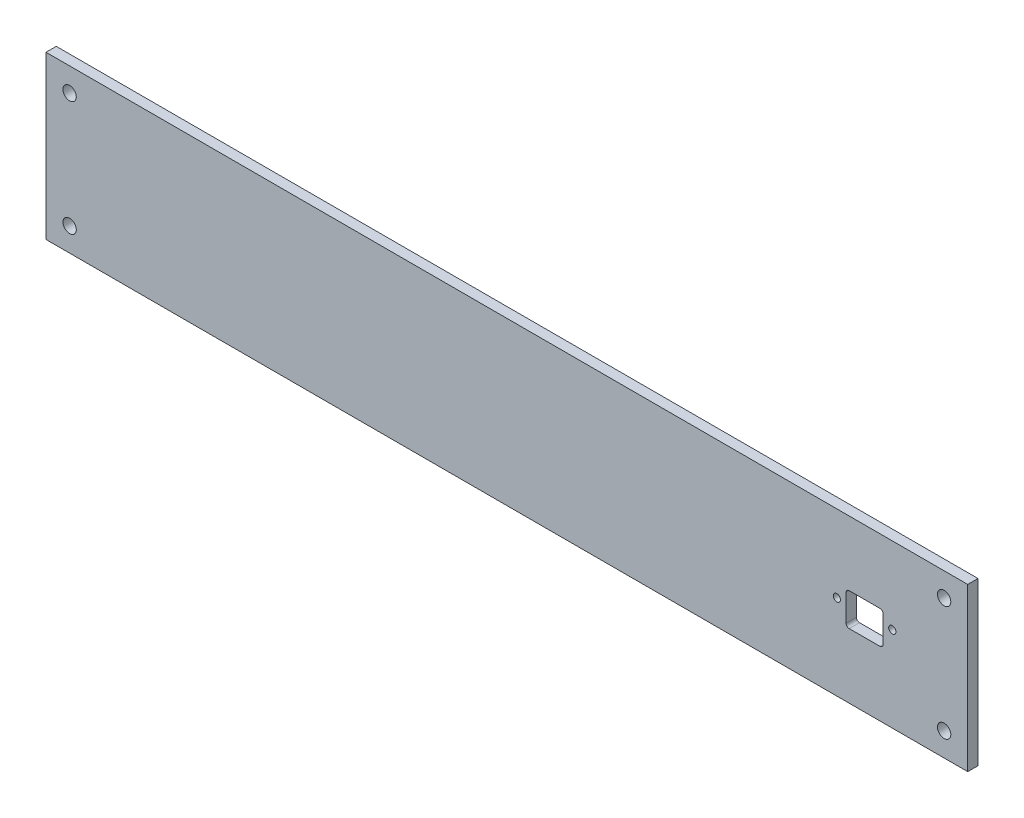
from build123d import *

# Parameters (mm, degrees)
SKETCH_F_W                   = 449
SKETCH_F_H                   = 79
SKETCH_F_R                   = 3.25
SKETCH_F_R_2                 = 1.75
ESTRUSIONE_ESTRUSIONE1_DEPTH = 5


with BuildPart() as part:
    # Sketch f → Estrusione-Estrusione1 (new body)
    with BuildSketch(Plane.XY):
        with Locations((224.5, 39.5)):
            Rectangle(SKETCH_F_W, SKETCH_F_H)
        with Locations((11.5, 67.5)):
            Circle(SKETCH_F_R, mode=Mode.SUBTRACT)
        with Locations((437.5, 67.5)):
            Circle(SKETCH_F_R, mode=Mode.SUBTRACT)
        with Locations((11.5, 11.5)):
            Circle(SKETCH_F_R, mode=Mode.SUBTRACT)
        with Locations((437.5, 11.5)):
            Circle(SKETCH_F_R, mode=Mode.SUBTRACT)
        with Locations((385.246939646, 41.5)):
            Circle(SKETCH_F_R_2, mode=Mode.SUBTRACT)
        with Locations((412.246939646, 41.5)):
            Circle(SKETCH_F_R_2, mode=Mode.SUBTRACT)
        with BuildLine():
            Line((407.746939646, 33), (407.746939646, 46))
            ThreePointArc((407.746939646, 46), (407.307599818, 47.060660172), (406.246939646, 47.5))
            Line((406.246939646, 47.5), (391.246939646, 47.5))
            ThreePointArc((391.246939646, 47.5), (390.186279474, 47.060660172), (389.746939646, 46))
            Line((389.746939646, 46), (389.746939646, 33))
            ThreePointArc((389.746939646, 33), (390.186279474, 31.939339828), (391.246939646, 31.5))
            Line((391.246939646, 31.5), (406.246939646, 31.5))
            ThreePointArc((406.246939646, 31.5), (407.307599818, 31.939339828), (407.746939646, 33))
        make_face(mode=Mode.SUBTRACT)
    extrude(amount=ESTRUSIONE_ESTRUSIONE1_DEPTH)


solid = part.part
